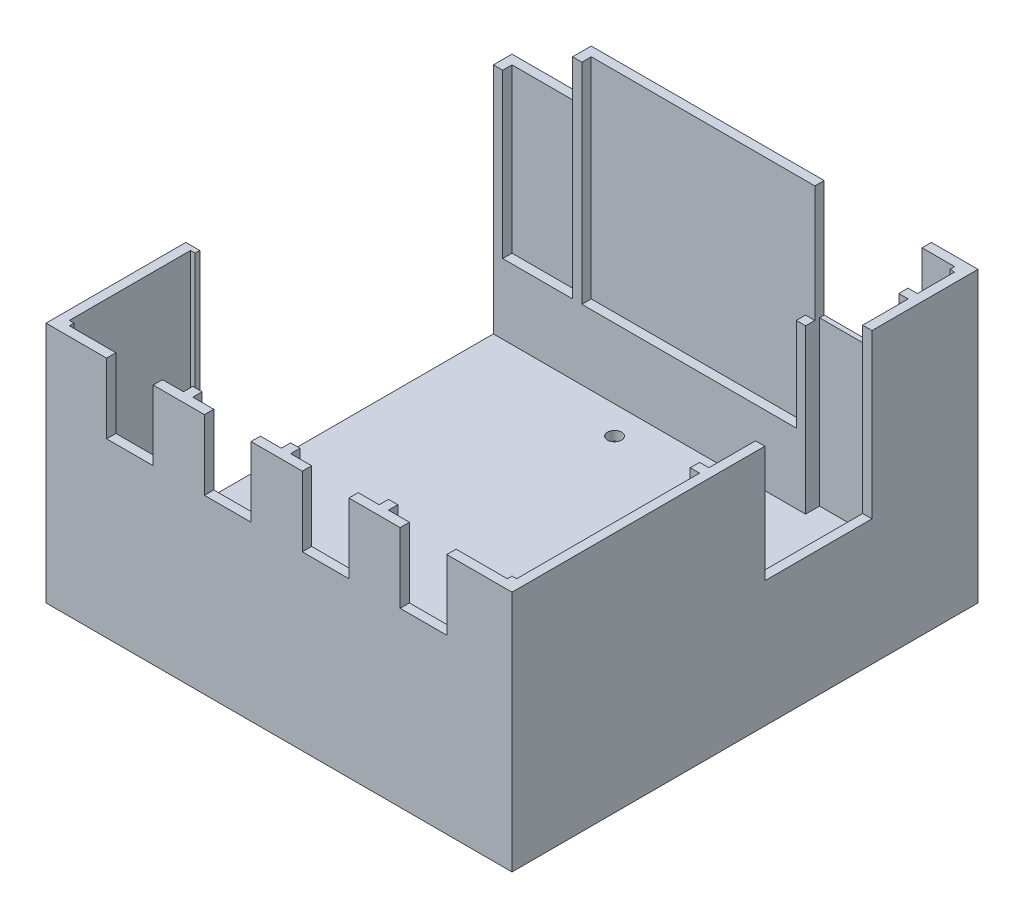
from build123d import *

# Parameters (mm, degrees)
SKICA1_W                  = 100
SKICA1_H                  = 100
P_IDAT_VYSUNUT_M1_DEPTH   = 3
SKICA2_R                  = 1.5
ODEBRAT_VYSUNUT_M5_DEPTH  = 3
SKICA3_W                  = 75
SKICA3_H                  = 2
P_IDAT_VYSUNUT_M4_DEPTH   = 53
SKICA10_W                 = 8
SKICA10_H                 = 2
ODEBRAT_VYSUNUT_M6_DEPTH  = 50
SKICA11_W                 = 10
SKICA11_H                 = 2
ODEBRAT_VYSUNUT_M8_DEPTH  = 15
SKICA16_W                 = 67
SKICA16_H                 = 2
P_IDAT_VYSUNUT_M6_DEPTH   = 15
SKICA17_W                 = 2.5
SKICA17_H                 = 2.5
P_IDAT_VYSUNUT_M7_DEPTH   = 15
SKICA18_W                 = 2.5
SKICA18_H                 = 2.5
P_IDAT_VYSUNUT_M8_DEPTH   = 15
SKICA19_W                 = 1
SKICA19_H                 = 1
P_IDAT_VYSUNUT_M10_DEPTH  = 50
SKICA20_W                 = 1
SKICA20_H                 = 1
P_IDAT_VYSUNUT_M11_DEPTH  = 35
SKICA21_W                 = 1
SKICA21_H                 = 1
P_IDAT_VYSUNUT_M12_DEPTH  = 35
SKICA22_W                 = 1
SKICA22_H                 = 1
P_IDAT_VYSUNUT_M13_DEPTH  = 50
SKICA24_W                 = 91
SKICA24_H                 = 2
P_IDAT_VYSUNUT_M14_DEPTH  = 15
SKICA25_W                 = 2
SKICA25_H                 = 2
P_IDAT_VYSUNUT_M15_DEPTH  = 35
SKICA26_W                 = 2
SKICA26_H                 = 2
P_IDAT_VYSUNUT_M16_DEPTH  = 35
SKICA27_W                 = 2
SKICA27_H                 = 49.75
P_IDAT_VYSUNUT_M17_DEPTH  = 15
SKICA28_W                 = 100
SKICA28_H                 = 5
P_IDAT_VYSUNUT_M18_DEPTH  = 5
SKICA30_W                 = 5
SKICA30_H                 = 90
P_IDAT_VYSUNUT_M19_DEPTH  = 5
SKICA31_W                 = 100
SKICA31_H                 = 100
ODEBRAT_VYSUNUT_M9_DEPTH  = 6
SKICA32_W                 = 2
SKICA32_H                 = 15
ODEBRAT_VYSUNUT_M10_DEPTH = 6
SKICA33_W                 = 2
SKICA33_H                 = 23
P_IDAT_VYSUNUT_M22_DEPTH  = 25
P_IDAT_VYSUNUT_M23_DEPTH  = 10
SKICA35_W                 = 50
SKICA35_H                 = 2
P_IDAT_VYSUNUT_M24_DEPTH  = 10
SKICA36_W                 = 2
SKICA36_H                 = 45
P_IDAT_VYSUNUT_M25_DEPTH  = 2
SKICA37_W                 = 2
SKICA37_H                 = 2
P_IDAT_VYSUNUT_M26_DEPTH  = 60
SKICA38_W                 = 10
SKICA38_H                 = 1
P_IDAT_VYSUNUT_M27_DEPTH  = 35
SKICA40_W                 = 2
SKICA40_H                 = 2
P_IDAT_VYSUNUT_M29_DEPTH  = 35


with BuildPart() as part:
    # Skica1 → Přidat vysunutím1 (new body)
    with BuildSketch(Plane(origin=(0, 0, 0), x_dir=(1, 0, 0), z_dir=(0, 1, 0))):
        Rectangle(SKICA1_W, SKICA1_H)
    extrude(amount=P_IDAT_VYSUNUT_M1_DEPTH)

    # Skica2 → Odebrat vysunutím5 (cut)
    with BuildSketch(Plane(origin=(0, 0, 0), x_dir=(1, 0, 0), z_dir=(0, 1, 0))):
        with Locations((-18, 40)):
            Circle(SKICA2_R)
        with Locations((40, 40)):
            Circle(SKICA2_R)
        with Locations((40, -8.5)):
            Circle(SKICA2_R)
        with Locations((-18, -8.5)):
            Circle(SKICA2_R)
    extrude(amount=ODEBRAT_VYSUNUT_M5_DEPTH, mode=Mode.SUBTRACT)

    # Skica3 → Přidat vysunutím4 (add)
    with BuildSketch(Plane(origin=(0, 0, 0), x_dir=(1, 0, 0), z_dir=(0, 1, 0))):
        Polygon((40, 50), (40, 48), (48, 48), (48, 27.25), (50, 27.25), (50, 50), align=None)
        Polygon((-50, -20), (-48, -20), (-48, -48), (48, -48), (48, 4.25), (50, 4.25), (50, -50), (-50, -50), align=None)
        with Locations((-12.5, 49)):
            Rectangle(SKICA3_W, SKICA3_H)
    extrude(amount=P_IDAT_VYSUNUT_M4_DEPTH)

    # Skica10 → Odebrat vysunutím6 (cut)
    with BuildSketch(Plane(origin=(0, 53, 0), x_dir=(1, 0, 0), z_dir=(0, 1, 0))):
        with Locations((21, 49)):
            Rectangle(SKICA10_W, SKICA10_H)
    extrude(amount=-ODEBRAT_VYSUNUT_M6_DEPTH, mode=Mode.SUBTRACT)

    # Skica11 → Odebrat vysunutím8 (cut)
    with BuildSketch(Plane(origin=(0, 53, 0), x_dir=(1, 0, 0), z_dir=(0, 1, 0))):
        with Locations((-32, -49)):
            Rectangle(SKICA11_W, SKICA11_H)
        with Locations((-11, -49)):
            Rectangle(SKICA11_W, SKICA11_H)
        with Locations((10, -49)):
            Rectangle(SKICA11_W, SKICA11_H)
        with Locations((31, -49)):
            Rectangle(SKICA11_W, SKICA11_H)
    extrude(amount=-ODEBRAT_VYSUNUT_M8_DEPTH, mode=Mode.SUBTRACT)

    # Skica16 → Přidat vysunutím6 (add)
    with BuildSketch(Plane(origin=(0, 3, 0), x_dir=(1, 0, 0), z_dir=(0, 1, 0))):
        with Locations((-16.5, 47)):
            Rectangle(SKICA16_W, SKICA16_H)
    extrude(amount=P_IDAT_VYSUNUT_M6_DEPTH)

    # Skica17 → Přidat vysunutím7 (add)
    with BuildSketch(Plane(origin=(0, 3, 0), x_dir=(1, 0, 0), z_dir=(0, 1, 0))):
        with Locations((46.75, -46.75)):
            Rectangle(SKICA17_W, SKICA17_H)
    extrude(amount=P_IDAT_VYSUNUT_M7_DEPTH)

    # Skica18 → Přidat vysunutím8 (add)
    with BuildSketch(Plane(origin=(0, 3, 0), x_dir=(1, 0, 0), z_dir=(0, 1, 0))):
        with Locations((-46.75, -46.75)):
            Rectangle(SKICA18_W, SKICA18_H)
    extrude(amount=P_IDAT_VYSUNUT_M8_DEPTH)

    # Skica19 → Přidat vysunutím10 (add)
    with BuildSketch(Plane(origin=(0, 3, 0), x_dir=(1, 0, 0), z_dir=(0, 1, 0))):
        with Locations((47.5, 47.5)):
            Rectangle(SKICA19_W, SKICA19_H)
    extrude(amount=P_IDAT_VYSUNUT_M10_DEPTH)

    # Skica20 → Přidat vysunutím11 (add)
    with BuildSketch(Plane(origin=(0, 18, 0), x_dir=(1, 0, 0), z_dir=(0, 1, 0))):
        with Locations((47.5, -47.5)):
            Rectangle(SKICA20_W, SKICA20_H)
    extrude(amount=P_IDAT_VYSUNUT_M11_DEPTH)

    # Skica21 → Přidat vysunutím12 (add)
    with BuildSketch(Plane(origin=(0, 18, 0), x_dir=(1, 0, 0), z_dir=(0, 1, 0))):
        with Locations((-47.5, -47.5)):
            Rectangle(SKICA21_W, SKICA21_H)
    extrude(amount=P_IDAT_VYSUNUT_M12_DEPTH)

    # Skica22 → Přidat vysunutím13 (add)
    with BuildSketch(Plane(origin=(0, 3, 0), x_dir=(1, 0, 0), z_dir=(0, 1, 0))):
        with Locations((-47.5, -20.5)):
            Rectangle(SKICA22_W, SKICA22_H)
    extrude(amount=P_IDAT_VYSUNUT_M13_DEPTH)

    # Skica24 → Přidat vysunutím14 (add)
    with BuildSketch(Plane(origin=(0, 3, 0), x_dir=(1, 0, 0), z_dir=(0, 1, 0))):
        with Locations((0, -47)):
            Rectangle(SKICA24_W, SKICA24_H)
    extrude(amount=P_IDAT_VYSUNUT_M14_DEPTH)

    # Skica25 → Přidat vysunutím15 (add)
    with BuildSketch(Plane(origin=(0, 18, 0), x_dir=(1, 0, 0), z_dir=(0, 1, 0))):
        with Locations((20.5, -47)):
            Rectangle(SKICA25_W, SKICA25_H)
        with Locations((-0.5, -47)):
            Rectangle(SKICA25_W, SKICA25_H)
        with Locations((-21.5, -47)):
            Rectangle(SKICA25_W, SKICA25_H)
    extrude(amount=P_IDAT_VYSUNUT_M15_DEPTH)

    # Skica26 → Přidat vysunutím16 (add)
    with BuildSketch(Plane(origin=(0, 18, 0), x_dir=(1, 0, 0), z_dir=(0, 1, 0))):
        with Locations((-49, 47)):
            Rectangle(SKICA26_W, SKICA26_H)
        with Locations((16, 47)):
            Rectangle(SKICA26_W, SKICA26_H)
    extrude(amount=P_IDAT_VYSUNUT_M16_DEPTH)

    # Skica27 → Přidat vysunutím17 (add)
    with BuildSketch(Plane(origin=(0, 3, 0), x_dir=(1, 0, 0), z_dir=(0, 1, 0))):
        with Locations((47, -20.625)):
            Rectangle(SKICA27_W, SKICA27_H)
    extrude(amount=P_IDAT_VYSUNUT_M17_DEPTH)

    # Skica28 → Přidat vysunutím18 (add)
    with BuildSketch(Plane(origin=(0, 0, 0), x_dir=(1, 0, 0), z_dir=(0, 1, 0))):
        with Locations((0, -47.5)):
            Rectangle(SKICA28_W, SKICA28_H)
        with Locations((0, 47.5)):
            Rectangle(SKICA28_W, SKICA28_H)
    extrude(amount=-P_IDAT_VYSUNUT_M18_DEPTH)

    # Skica30 → Přidat vysunutím19 (add)
    with BuildSketch(Plane(origin=(0, 0, 0), x_dir=(-1, 0, 0), z_dir=(0, -1, 0))):
        with Locations((47.5, 0)):
            Rectangle(SKICA30_W, SKICA30_H)
        with Locations((-47.5, 0)):
            Rectangle(SKICA30_W, SKICA30_H)
    extrude(amount=P_IDAT_VYSUNUT_M19_DEPTH)

    # Skica31 → Odebrat vysunutím9 (cut)
    with BuildSketch(Plane(origin=(0, -5, 0), x_dir=(-1, 0, 0), z_dir=(0, -1, 0))):
        Rectangle(SKICA31_W, SKICA31_H)
    extrude(amount=-ODEBRAT_VYSUNUT_M9_DEPTH, mode=Mode.SUBTRACT)

    # Skica32 → Odebrat vysunutím10 (cut)
    with BuildSketch(Plane.ZY.offset(-15)):
        with Locations((-47, 45.5)):
            Rectangle(SKICA32_W, SKICA32_H)
    extrude(amount=-ODEBRAT_VYSUNUT_M10_DEPTH, mode=Mode.SUBTRACT)

    # Skica33 → Přidat vysunutím22 (add)
    with BuildSketch(Plane(origin=(0, 3, 0), x_dir=(1, 0, 0), z_dir=(0, 1, 0))):
        with Locations((49, 15.75)):
            Rectangle(SKICA33_W, SKICA33_H)
    extrude(amount=P_IDAT_VYSUNUT_M22_DEPTH)

    # Skica34 → Přidat vysunutím23 (add)
    with BuildSketch(Plane(origin=(0, 53, 0), x_dir=(1, 0, 0), z_dir=(0, 1, 0))):
        Polygon((40, 50), (50, 50), (50, 27.25), (48, 27.25), (48, 47), (47, 47), (47, 48), (40, 48), align=None)
    extrude(amount=P_IDAT_VYSUNUT_M23_DEPTH)

    # Skica35 → Přidat vysunutím24 (add)
    with BuildSketch(Plane(origin=(0, 53, 0), x_dir=(1, 0, 0), z_dir=(0, 1, 0))):
        with Locations((-8, 49)):
            Rectangle(SKICA35_W, SKICA35_H)
    extrude(amount=P_IDAT_VYSUNUT_M24_DEPTH)

    # Skica36 → Přidat vysunutím25 (add)
    with BuildSketch(Plane.XY.offset(-48)):
        with Locations((-32, 40.5)):
            Rectangle(SKICA36_W, SKICA36_H)
    extrude(amount=P_IDAT_VYSUNUT_M25_DEPTH)

    # Skica37 → Přidat vysunutím26 (add)
    with BuildSketch(Plane(origin=(0, 3, 0), x_dir=(1, 0, 0), z_dir=(0, 1, 0))):
        with Locations((47, 38)):
            Rectangle(SKICA37_W, SKICA37_H)
    extrude(amount=P_IDAT_VYSUNUT_M26_DEPTH)

    # Skica38 → Přidat vysunutím27 (add)
    with BuildSketch(Plane(origin=(0, 3, 0), x_dir=(1, 0, 0), z_dir=(0, 1, 0))):
        with Locations((22, 49.5)):
            Rectangle(SKICA38_W, SKICA38_H)
    extrude(amount=P_IDAT_VYSUNUT_M27_DEPTH)

    # Skica40 → Přidat vysunutím29 (add)
    with BuildSketch(Plane(origin=(0, 53, 0), x_dir=(1, 0, 0), z_dir=(0, 1, 0))):
        with Locations((47, -6.75)):
            Rectangle(SKICA40_W, SKICA40_H)
    extrude(amount=-P_IDAT_VYSUNUT_M29_DEPTH)


solid = part.part
